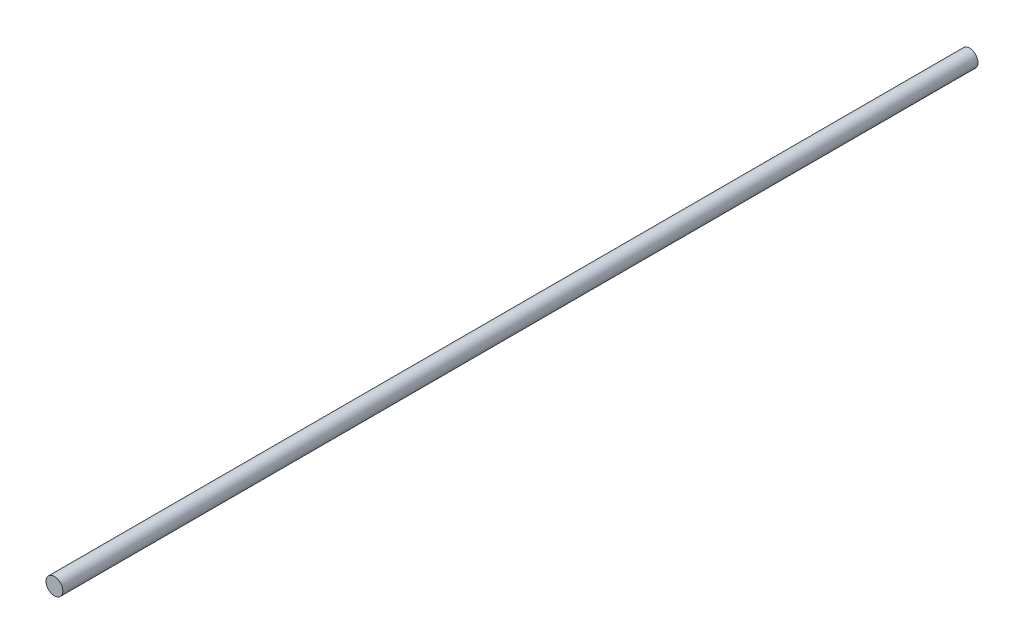
from build123d import *

# Parameters (mm, degrees)
SKETCH1_R           = 4
BOSS_EXTRUDE1_DEPTH = 435


with BuildPart() as part:
    # Sketch1 → Boss-Extrude1 (new body)
    with BuildSketch(Plane.XY):
        Circle(SKETCH1_R)
    extrude(amount=BOSS_EXTRUDE1_DEPTH)


solid = part.part
